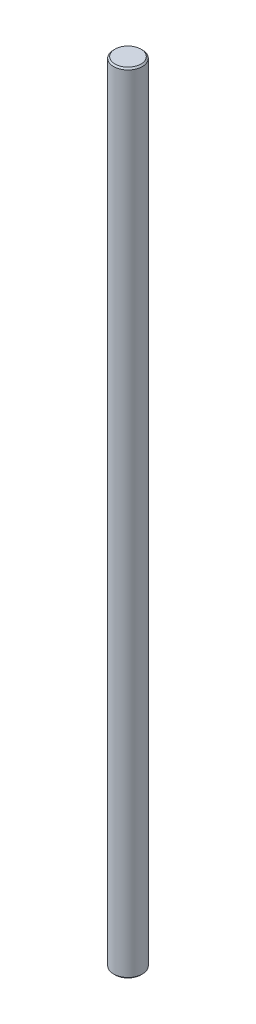
from build123d import *

# Parameters (mm, degrees)
MAINSKETCH_R             = 5
BOSS_EXTRUDE1_DEPTH      = 100
BOSS_EXTRUDE1_DEPTH_BACK = 174.307396978
CHAMFER1_SIZE            = 0.5


with BuildPart() as part:
    # MainSketch → Boss-Extrude1 (new body, two sides)
    with BuildSketch(Plane(origin=(0, 0, 0), x_dir=(1, 0, 0), z_dir=(0, 1, 0))) as boss_extrude1_sk:
        Circle(MAINSKETCH_R)
    extrude(amount=BOSS_EXTRUDE1_DEPTH)
    extrude(boss_extrude1_sk.sketch, amount=-BOSS_EXTRUDE1_DEPTH_BACK)

    # Chamfer1
    chamfer1_edges = [part.edges().sort_by_distance(p)[0] for p in [
        (-5, -174.307396978, 0),
        (-5, 100, 0),
    ]]
    chamfer(chamfer1_edges, length=CHAMFER1_SIZE)


solid = part.part
